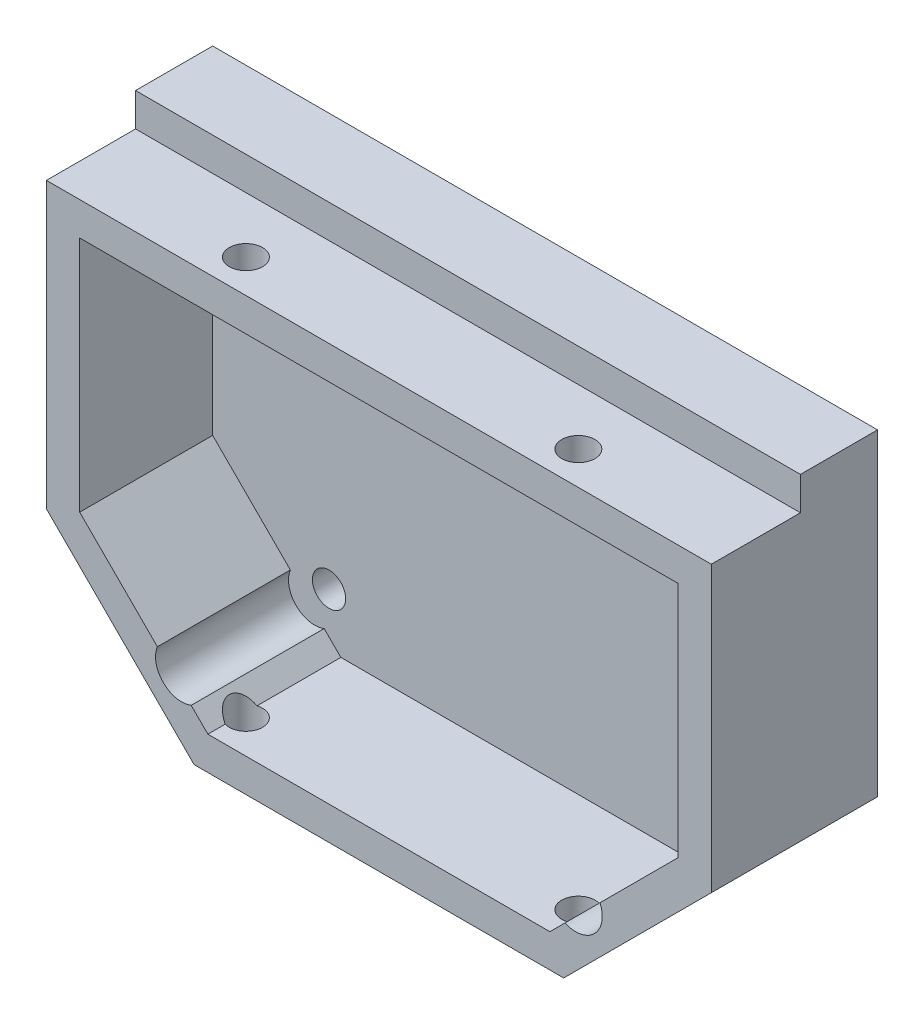
from build123d import *

# Parameters (mm, degrees)
BOSS_EXTRU_1_DEPTH              = 13
BOSS_EXTRU_1_DEPTH_BACK         = 12
COQUE1_T                        = -5
ESQUISSE3_R                     = 2.5
ENL_V_MAT_EXTRU_2_DEPTH         = 65
ESQUISSE5_R                     = 2.5
ENL_V_MAT_EXTRU_3_DEPTH         = 5
R_P_TITION_LIN_AIRE1_COUNT      = 2
R_P_TITION_LIN_AIRE1_PITCH      = 55
R_P_TITION_LIN_AIRE1_COUNT_DIR2 = 2
R_P_TITION_LIN_AIRE1_PITCH_DIR2 = 42
ENL_V_MAT_EXTRU_4_DEPTH         = 20
ESQUISSE8_W                     = 100
ESQUISSE8_H                     = 11.6
BOSS_EXTRU_2_DEPTH              = 5


with BuildPart() as part:
    # Esquisse1 → Boss.-Extru.1 (new body, two sides)
    with BuildSketch(Plane.XY) as boss_extru_1_sk:
        Polygon((44.118436308, 33.667601464), (51.949315251, 33.667601464), (51.949315251, -9.124565742), (29.741482457, -31.332398536), (-25.842851955, -31.332398536), (-48.050684749, -9.124565742), (-48.050684749, 33.667601464), align=None)
    extrude(amount=BOSS_EXTRU_1_DEPTH)
    extrude(boss_extru_1_sk.sketch, amount=-BOSS_EXTRU_1_DEPTH_BACK)

    # Coque1
    coque1_openings = [part.faces().sort_by_distance(p)[0] for p in [
        (1.949315251, -2.263120938, 13),
    ]]
    offset(amount=COQUE1_T, openings=coque1_openings, kind=Kind.INTERSECTION)

    # Esquisse3 → Enlèv. mat.-Extru.2 (cut)
    with BuildSketch(Plane.XZ.offset(31.332398536)):
        with Locations((-23.050684749, 8)):
            Circle(ESQUISSE3_R)
        with Locations((26.949315251, 8)):
            Circle(ESQUISSE3_R)
    extrude(amount=-ENL_V_MAT_EXTRU_2_DEPTH, mode=Mode.SUBTRACT)

    # Esquisse5 → Enlèv. mat.-Extru.3 (cut)
    with BuildSketch(Plane.XY.offset(-7)):
        with Locations((-25.550684749, 23.667601464)):
            Circle(ESQUISSE5_R)
    enl_v_mat_extru_3 = extrude(amount=-ENL_V_MAT_EXTRU_3_DEPTH, mode=Mode.SUBTRACT)

    # Répétition linéaire1: Enl_v. mat.-Extru.3 2 × 2
    with Locations(*[(i * R_P_TITION_LIN_AIRE1_PITCH, -j * R_P_TITION_LIN_AIRE1_PITCH_DIR2, 0) for i in range(R_P_TITION_LIN_AIRE1_COUNT) for j in range(R_P_TITION_LIN_AIRE1_COUNT_DIR2) if (i, j) != (0, 0)]):
        add(enl_v_mat_extru_3, mode=Mode.SUBTRACT)

    # Esquisse6 → Enlèv. mat.-Extru.4 (cut)
    with BuildSketch(Plane.XY.offset(13)):
        with BuildLine():
            Line((35.20468587, -18.798127311), (29.937348937, -24.065464245))
            ThreePointArc((29.937348937, -24.065464245), (34.372934866, -23.23371324), (35.20468587, -18.798127311))
        make_face()
        with BuildLine():
            Line((-31.365895508, -18.738287171), (-26.27917923, -23.825003449))
            ThreePointArc((-26.27917923, -23.825003449), (-30.493197573, -22.952305514), (-31.365895508, -18.738287171))
        make_face()
    extrude(amount=-ENL_V_MAT_EXTRU_4_DEPTH, mode=Mode.SUBTRACT)

    # Esquisse8 → Boss.-Extru.2 (add)
    with BuildSketch(Plane(origin=(0, 33.667601464, 0), x_dir=(1, 0, 0), z_dir=(0, 1, 0))):
        with Locations((1.949315251, 6.2)):
            Rectangle(ESQUISSE8_W, ESQUISSE8_H)
    extrude(amount=BOSS_EXTRU_2_DEPTH)


solid = part.part
